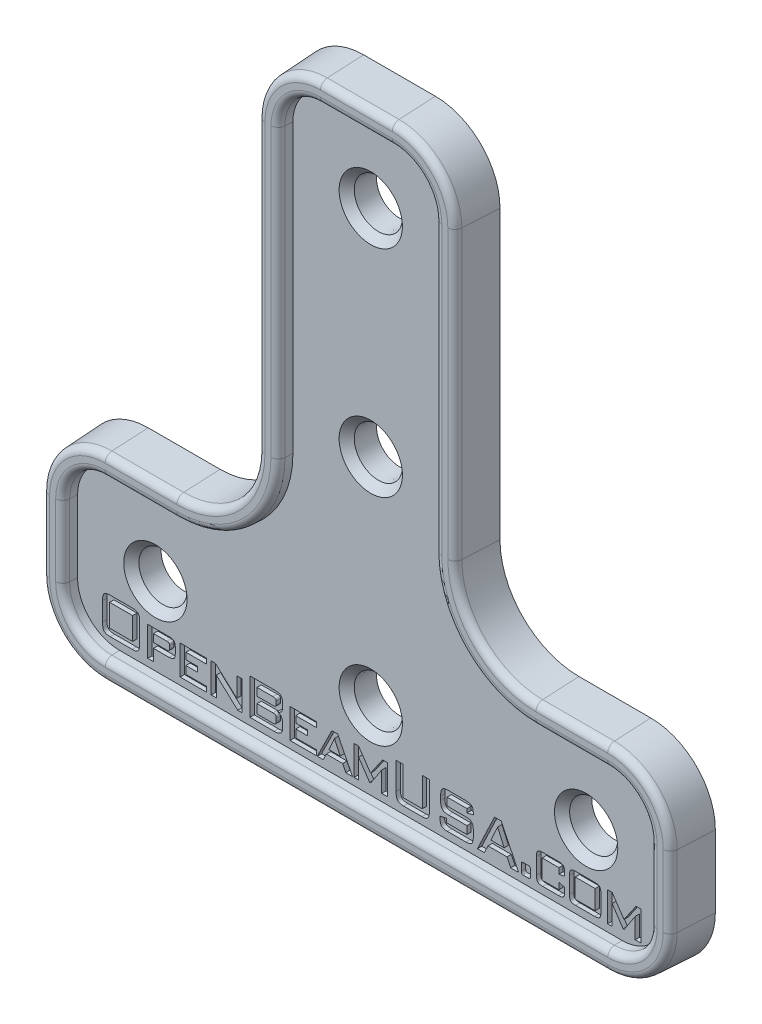
from build123d import *

# Parameters (mm, degrees)
BOSS_EXTRUDE1_DEPTH   = 2
FILLET1_R             = 5
SKETCH2_R             = 1.6
CUT_EXTRUDE1_DEPTH    = 38.553295461
MOVE_FACE1_BY         = 0.5
MOVE_FACE1_2_BY       = 0.5
MOVE_FACE1_3_BY       = 0.5
MOVE_FACE1_4_BY       = 0.5
MOVE_FACE1_5_BY       = 0.5
MOVE_FACE1_6_BY       = 0.5
MOVE_FACE1_7_BY       = 0.5
MOVE_FACE1_8_BY       = 0.5
MOVE_FACE1_9_BY       = 0.5
MOVE_FACE1_10_BY      = 0.5
MOVE_FACE1_11_BY      = 0.5
MOVE_FACE1_12_BY      = 0.5
MOVE_FACE1_13_BY      = 0.5
MOVE_FACE1_14_BY      = 0.5
MOVE_FACE1_15_BY      = 0.5
MOVE_FACE1_16_BY      = 0.5
DRAFT1_ANGLE          = -3
BOSS_EXTRUDE3_DEPTH   = 1
BOSS_EXTRUDE3_DRAFT   = 3
FILLET3_R             = 0.5
CUT_EXTRUDE2_DEPTH    = 0.2
CUT_EXTRUDE2_DRAFT    = -3
SKETCH6_W             = 1.607142857
SKETCH6_H             = 1.5625
SKETCH6_W_2           = 1.383928571
SKETCH6_H_2           = 1.339285714
CUT_EXTRUDE3_DEPTH    = 0.3
CHAMFER1_SIZE         = 0.5
CHAMFER1_SIZE2        = 0.528377251
CHAMFER1_EDGE_2_SIZE  = 0.5
CHAMFER1_EDGE_2_SIZE2 = 0.528377251
CHAMFER1_EDGE_3_SIZE  = 0.5
CHAMFER1_EDGE_3_SIZE2 = 0.528377251
CHAMFER1_EDGE_4_SIZE  = 0.5
CHAMFER1_EDGE_4_SIZE2 = 0.528377251
CHAMFER1_EDGE_5_SIZE  = 0.5
CHAMFER1_EDGE_5_SIZE2 = 0.528377251


with BuildPart() as part:
    # Sketch1 → Boss-Extrude1 (new body)
    with BuildSketch(Plane.XY):
        Polygon((-7.5, 30), (7.5, 30), (7.5, 0), (22.5, 0), (22.5, -15), (-22.5, -15), (-22.5, 0), (-7.5, 0), align=None)
    extrude(amount=BOSS_EXTRUDE1_DEPTH)

    # Fillet1
    fillet1_edges = [part.edges().sort_by_distance(p)[0] for p in [
        (-7.5, 30, 1),
        (7.5, 30, 1),
        (7.5, 0, 1),
        (22.5, 0, 1),
        (22.5, -15, 1),
        (-22.5, -15, 1),
        (-22.5, 0, 1),
        (-7.5, 0, 1),
    ]]
    fillet(fillet1_edges, radius=FILLET1_R)

    # Sketch2 → Cut-Extrude1 (cut, through all)
    with BuildSketch(Plane.XY.offset(2)):
        with Locations((-15, -7.5)):
            Circle(SKETCH2_R)
        with Locations((0, -7.5)):
            Circle(SKETCH2_R)
        with Locations((15, -7.5)):
            Circle(SKETCH2_R)
        with Locations((0, 22.5)):
            Circle(SKETCH2_R)
        with Locations((0, 7.5)):
            Circle(SKETCH2_R)
    extrude(amount=-CUT_EXTRUDE1_DEPTH, mode=Mode.SUBTRACT)

    # Move Face1: a curved face moved inward by 0.5
    add(Solid.thicken(part.faces().sort_by_distance((-8.964466094, 1.464466094, 1))[0], -MOVE_FACE1_BY), mode=Mode.SUBTRACT)

    # Move Face1 2: a face moved inward by 0.5
    extrude(part.faces().sort_by_distance((-15, 0, 1))[0], amount=MOVE_FACE1_2_BY, dir=(0, -1, 0), mode=Mode.SUBTRACT)

    # Move Face1 3: a curved face moved inward by 0.5
    add(Solid.thicken(part.faces().sort_by_distance((-21.035533906, -1.464466094, 1))[0], -MOVE_FACE1_3_BY), mode=Mode.SUBTRACT)

    # Move Face1 4: a face moved inward by 0.5
    extrude(part.faces().sort_by_distance((-22.5, -7.5, 1))[0], amount=MOVE_FACE1_4_BY, dir=(1, 0, 0), mode=Mode.SUBTRACT)

    # Move Face1 5: a curved face moved inward by 0.5
    add(Solid.thicken(part.faces().sort_by_distance((-21.035533906, -13.535533906, 1))[0], -MOVE_FACE1_5_BY), mode=Mode.SUBTRACT)

    # Move Face1 6: a face moved inward by 0.5
    extrude(part.faces().sort_by_distance((0, -15, 1))[0], amount=MOVE_FACE1_6_BY, dir=(0, 1, 0), mode=Mode.SUBTRACT)

    # Move Face1 7: a curved face moved inward by 0.5
    add(Solid.thicken(part.faces().sort_by_distance((21.035533906, -13.535533906, 1))[0], -MOVE_FACE1_7_BY), mode=Mode.SUBTRACT)

    # Move Face1 8: a face moved inward by 0.5
    extrude(part.faces().sort_by_distance((22.5, -7.5, 1))[0], amount=MOVE_FACE1_8_BY, dir=(-1, 0, 0), mode=Mode.SUBTRACT)

    # Move Face1 9: a curved face moved inward by 0.5
    add(Solid.thicken(part.faces().sort_by_distance((21.035533906, -1.464466094, 1))[0], -MOVE_FACE1_9_BY), mode=Mode.SUBTRACT)

    # Move Face1 10: a face moved inward by 0.5
    extrude(part.faces().sort_by_distance((15, 0, 1))[0], amount=MOVE_FACE1_10_BY, dir=(0, -1, 0), mode=Mode.SUBTRACT)

    # Move Face1 11: a curved face moved inward by 0.5
    add(Solid.thicken(part.faces().sort_by_distance((8.964466094, 1.464466094, 1))[0], -MOVE_FACE1_11_BY), mode=Mode.SUBTRACT)

    # Move Face1 12: a face moved inward by 0.5
    extrude(part.faces().sort_by_distance((7.5, 15, 1))[0], amount=MOVE_FACE1_12_BY, dir=(-1, 0, 0), mode=Mode.SUBTRACT)

    # Move Face1 13: a curved face moved inward by 0.5
    add(Solid.thicken(part.faces().sort_by_distance((6.035533906, 28.535533906, 1))[0], -MOVE_FACE1_13_BY), mode=Mode.SUBTRACT)

    # Move Face1 14: a face moved inward by 0.5
    extrude(part.faces().sort_by_distance((0, 30, 1))[0], amount=MOVE_FACE1_14_BY, dir=(0, -1, 0), mode=Mode.SUBTRACT)

    # Move Face1 15: a curved face moved inward by 0.5
    add(Solid.thicken(part.faces().sort_by_distance((-6.035533906, 28.535533906, 1))[0], -MOVE_FACE1_15_BY), mode=Mode.SUBTRACT)

    # Move Face1 16: a face moved inward by 0.5
    extrude(part.faces().sort_by_distance((-7.5, 15, 1))[0], amount=MOVE_FACE1_16_BY, dir=(1, 0, 0), mode=Mode.SUBTRACT)

    # Draft1
    draft1_faces = [part.faces().sort_by_distance(p)[0] for p in [
        (13.4, -7.5, 1),
        (-1.6, 22.5, 1),
        (-1.6, 7.5, 1),
        (-1.6, -7.5, 1),
        (-16.6, -7.5, 1),
        (-20.681980515, -1.818019485, 1),
        (-22, -7.5, 1),
        (-20.681980515, -13.181980515, 1),
        (0, -14.5, 1),
        (20.681980515, -13.181980515, 1),
        (22, -7.5, 1),
        (20.681980515, -1.818019485, 1),
        (15, -0.5, 1),
        (8.610912703, 1.110912703, 1),
        (7, 15, 1),
        (5.681980515, 28.181980515, 1),
        (0, 29.5, 1),
        (-5.681980515, 28.181980515, 1),
        (-7, 15, 1),
        (-8.610912703, 1.110912703, 1),
        (-15, -0.5, 1),
    ]]
    draft(draft1_faces, Plane(origin=(0, 0, 0), x_dir=(-1, 0, 0), z_dir=(0, 0, -1)), DRAFT1_ANGLE)


with BuildPart() as boss_extrude3_tool:
    # Sketch4 → Boss-Extrude3 (with draft: the straight prism first)
    with BuildSketch(Plane.XY.offset(2)):
        with BuildLine():
            Line((-17.5, -14.395184441), (17.5, -14.395184441))
            ThreePointArc((17.5, -14.395184441), (20.607864723, -13.107864723), (21.895184441, -10))
            Line((21.895184441, -10), (21.895184441, -5))
            ThreePointArc((21.895184441, -5), (20.607864723, -1.892135277), (17.5, -0.604815559))
            Line((17.5, -0.604815559), (12.5, -0.604815559))
            ThreePointArc((12.5, -0.604815559), (8.536796911, 1.036796911), (6.895184441, 5))
            Line((6.895184441, 5), (6.895184441, 25))
            ThreePointArc((6.895184441, 25), (5.607864723, 28.107864723), (2.5, 29.395184441))
            Line((2.5, 29.395184441), (-2.5, 29.395184441))
            ThreePointArc((-2.5, 29.395184441), (-5.607864723, 28.107864723), (-6.895184441, 25))
            Line((-6.895184441, 25), (-6.895184441, 5))
            ThreePointArc((-6.895184441, 5), (-8.536796911, 1.036796911), (-12.5, -0.604815559))
            Line((-12.5, -0.604815559), (-17.5, -0.604815559))
            ThreePointArc((-17.5, -0.604815559), (-20.607864723, -1.892135277), (-21.895184441, -5))
            Line((-21.895184441, -5), (-21.895184441, -10))
            ThreePointArc((-21.895184441, -10), (-20.607864723, -13.107864723), (-17.5, -14.395184441))
        make_face()
        with BuildLine():
            Line((-17.5, -12.921388331), (17.5, -12.921388331))
            ThreePointArc((17.5, -12.921388331), (19.565733499, -12.065733499), (20.421388331, -10))
            Line((20.421388331, -10), (20.421388331, -5))
            ThreePointArc((20.421388331, -5), (19.565733499, -2.934266501), (17.5, -2.078611669))
            Line((17.5, -2.078611669), (12.5, -2.078611669))
            ThreePointArc((12.5, -2.078611669), (7.494665688, -0.005334312), (5.421388331, 5))
            Line((5.421388331, 5), (5.421388331, 25))
            ThreePointArc((5.421388331, 25), (4.565733499, 27.065733499), (2.5, 27.921388331))
            Line((2.5, 27.921388331), (-2.5, 27.921388331))
            ThreePointArc((-2.5, 27.921388331), (-4.565733499, 27.065733499), (-5.421388331, 25))
            Line((-5.421388331, 25), (-5.421388331, 5))
            ThreePointArc((-5.421388331, 5), (-7.494665688, -0.005334312), (-12.5, -2.078611669))
            Line((-12.5, -2.078611669), (-17.5, -2.078611669))
            ThreePointArc((-17.5, -2.078611669), (-19.565733499, -2.934266501), (-20.421388331, -5))
            Line((-20.421388331, -5), (-20.421388331, -10))
            ThreePointArc((-20.421388331, -10), (-19.565733499, -12.065733499), (-17.5, -12.921388331))
        make_face(mode=Mode.SUBTRACT)
    extrude(amount=BOSS_EXTRUDE3_DEPTH)
    # Boss-Extrude3: the draft: its side faces are tilted about the plane it starts from
    boss_extrude3_sides = [boss_extrude3_tool.faces().sort_by_distance(p)[0] for p in [
        (-20.607864723, -1.892135277, 2.5),
        (-21.895184441, -7.5, 2.5),
        (-20.607864723, -13.107864723, 2.5),
        (0, -14.395184441, 2.5),
        (20.607864723, -13.107864723, 2.5),
        (21.895184441, -7.5, 2.5),
        (20.607864723, -1.892135277, 2.5),
        (15, -0.604815559, 2.5),
        (8.536796911, 1.036796911, 2.5),
        (6.895184441, 15, 2.5),
        (5.607864723, 28.107864723, 2.5),
        (0, 29.395184441, 2.5),
        (-5.607864723, 28.107864723, 2.5),
        (-6.895184441, 15, 2.5),
        (-8.536796911, 1.036796911, 2.5),
        (-15, -0.604815559, 2.5),
        (-15, -2.078611669, 2.5),
        (-7.494665688, -0.005334312, 2.5),
        (-5.421388331, 15, 2.5),
        (-4.565733499, 27.065733499, 2.5),
        (0, 27.921388331, 2.5),
        (4.565733499, 27.065733499, 2.5),
        (5.421388331, 15, 2.5),
        (7.494665688, -0.005334312, 2.5),
        (15, -2.078611669, 2.5),
        (19.565733499, -2.934266501, 2.5),
        (20.421388331, -7.5, 2.5),
        (19.565733499, -12.065733499, 2.5),
        (0, -12.921388331, 2.5),
        (-19.565733499, -12.065733499, 2.5),
        (-20.421388331, -7.5, 2.5),
        (-19.565733499, -2.934266501, 2.5),
    ]]
    draft(boss_extrude3_sides, Plane.XY.offset(2), BOSS_EXTRUDE3_DRAFT)


with BuildPart() as part_1:
    add(part.part)

    # Boss-Extrude3: add boss_extrude3_tool
    add(boss_extrude3_tool.part)

    # Fillet3
    fillet3_edges = [part_1.edges().sort_by_distance(p)[0] for p in [
        (-20.570806827, -13.070806827, 3),
        (0, -14.342776662, 3),
        (20.570806827, -13.070806827, 3),
        (21.842776662, -7.5, 3),
        (20.570806827, -1.929193173, 3),
        (15, -0.657223338, 3),
        (8.499739015, 0.999739015, 3),
        (6.842776662, 15, 3),
        (5.570806827, 28.070806827, 3),
        (0, 29.342776662, 3),
        (-5.570806827, 28.070806827, 3),
        (-6.842776662, 15, 3),
        (-8.499739015, 0.999739015, 3),
        (-15, -0.657223338, 3),
        (-20.570806827, -1.929193173, 3),
        (-21.842776662, -7.5, 3),
        (-19.602791396, -12.102791396, 3),
        (0, -12.97379611, 3),
        (19.602791396, -12.102791396, 3),
        (20.47379611, -7.5, 3),
        (19.602791396, -2.897208604, 3),
        (15, -2.02620389, 3),
        (7.531723584, 0.031723584, 3),
        (5.47379611, 15, 3),
        (4.602791396, 27.102791396, 3),
        (0, 27.97379611, 3),
        (-4.602791396, 27.102791396, 3),
        (-5.47379611, 15, 3),
        (-7.531723584, 0.031723584, 3),
        (-15, -2.02620389, 3),
        (-19.602791396, -2.897208604, 3),
        (-20.47379611, -7.5, 3),
    ]]
    fillet(fillet3_edges, radius=FILLET3_R)


with BuildPart() as cut_extrude2_tool:
    # Sketch5 → Cut-Extrude2 (with draft: the straight prism first)
    with BuildSketch(Plane(origin=(0, 0, 0), x_dir=(-1, 0, 0), z_dir=(0, 0, -1))):
        with BuildLine():
            Line((-14.5, -13.8), (14.5, -13.8))
            ThreePointArc((14.5, -13.8), (14.853553391, -13.653553391), (15, -13.3))
            Line((15, -13.3), (15, -10.3))
            ThreePointArc((15, -10.3), (14.853553391, -9.946446609), (14.5, -9.8))
            Line((14.5, -9.8), (-14.5, -9.8))
            ThreePointArc((-14.5, -9.8), (-14.853553391, -9.946446609), (-15, -10.3))
            Line((-15, -10.3), (-15, -13.3))
            ThreePointArc((-15, -13.3), (-14.853553391, -13.653553391), (-14.5, -13.8))
        make_face()
    extrude(amount=-CUT_EXTRUDE2_DEPTH)
    # Cut-Extrude2: the draft: its side faces are tilted about the plane it starts from
    cut_extrude2_sides = [cut_extrude2_tool.faces().sort_by_distance(p)[0] for p in [
        (0, -13.8, 0.1),
        (-14.853553391, -13.653553391, 0.1),
        (-15, -11.8, 0.1),
        (-14.853553391, -9.946446609, 0.1),
        (0, -9.8, 0.1),
        (14.853553391, -9.946446609, 0.1),
        (15, -11.8, 0.1),
        (14.853553391, -13.653553391, 0.1),
    ]]
    draft(cut_extrude2_sides, Plane(origin=(0, 0, 0), x_dir=(-1, 0, 0), z_dir=(0, 0, -1)), CUT_EXTRUDE2_DRAFT)


with BuildPart() as part_2:
    add(part_1.part)

    # Cut-Extrude2: cut by cut_extrude2_tool
    add(cut_extrude2_tool.part, mode=Mode.SUBTRACT)

    # Sketch6 → Cut-Extrude3 (cut)
    with BuildSketch(Plane.XY.offset(2)):
        with BuildLine():
            add(Edge.make_bspline(
                [(-18.683035714, -10.51011601), (-18.682938002, -10.482896819), (-18.682750693, -10.430719031), (-18.676668044, -10.356042819), (-18.668860697, -10.287926096), (-18.656684431, -10.226526586), (-18.643031263, -10.171215857), (-18.623628363, -10.123356935), (-18.602261682, -10.081592118), (-18.57683028, -10.045679654), (-18.545847467, -10.01549167), (-18.508789269, -9.990400409), (-18.46597857, -9.968617372), (-18.416580048, -9.951568957), (-18.361320255, -9.937537726), (-18.299893333, -9.928095322), (-18.232289845, -9.922620499), (-18.185232384, -9.921811984), (-18.160574777, -9.921388331)],
                knots=[0, 0, 0, 0, 1.403573437, 2.690578007, 3.862923789, 4.937964027, 5.918444779, 6.796020214, 7.595440406, 8.334448064, 9.055422419, 9.814027648, 10.634759978, 11.526322857, 12.50379092, 13.57259004, 14.728063101, 16, 16, 16, 16], degree=3))
            Line((-18.160574777, -9.921388331), (-16.618303571, -9.921388331))
            add(Edge.make_bspline(
                [(-16.618303571, -9.921388331), (-16.593646851, -9.921821445), (-16.546359359, -9.922652086), (-16.47851397, -9.928042886), (-16.416866585, -9.937552288), (-16.361581808, -9.951531158), (-16.312067564, -9.968807094), (-16.268818434, -9.990195221), (-16.231663242, -10.015520924), (-16.200589368, -10.045644028), (-16.175401388, -10.081803336), (-16.152770043, -10.122971899), (-16.134936302, -10.1715459), (-16.119750579, -10.226353255), (-16.108035577, -10.28796068), (-16.100083866, -10.356032245), (-16.094044728, -10.430722068), (-16.09385104, -10.48289786), (-16.09375, -10.51011601)],
                knots=[0, 0, 0, 0, 1.269785572, 2.435237667, 3.502229043, 4.478043838, 5.368098746, 6.198135559, 6.9554577, 7.675212615, 8.41297033, 9.216677895, 10.088421144, 11.070387939, 12.143609877, 13.313972779, 14.598800537, 16, 16, 16, 16], degree=3))
            Line((-16.09375, -10.51011601), (-16.09375, -11.811036769))
            add(Edge.make_bspline(
                [(-16.09375, -11.811036769), (-16.093842278, -11.839417739), (-16.09401872, -11.893684241), (-16.100160957, -11.971615929), (-16.107923834, -12.042494992), (-16.119768025, -12.106636793), (-16.134983627, -12.163512713), (-16.152647685, -12.213987832), (-16.175226782, -12.256626432), (-16.200584268, -12.293600425), (-16.231614851, -12.324447097), (-16.268765478, -12.35050105), (-16.312034652, -12.372539497), (-16.361440049, -12.390711436), (-16.416882029, -12.404519647), (-16.478547615, -12.413833116), (-16.546317858, -12.420380788), (-16.593639586, -12.421043123), (-16.618303571, -12.421388331)],
                knots=[0, 0, 0, 0, 1.431764632, 2.737639174, 3.942781974, 5.02906717, 6.025299976, 6.912532689, 7.72083079, 8.453349384, 9.16691991, 9.91579719, 10.734504626, 11.610727997, 12.566975227, 13.612570717, 14.755676853, 16, 16, 16, 16], degree=3))
            Line((-16.618303571, -12.421388331), (-18.160574777, -12.421388331))
            add(Edge.make_bspline(
                [(-18.160574777, -12.421388331), (-18.185239843, -12.421053786), (-18.232332055, -12.420415051), (-18.299858951, -12.413778337), (-18.36130513, -12.404534983), (-18.416721056, -12.39067324), (-18.466016648, -12.372733543), (-18.508837175, -12.350292386), (-18.545896228, -12.324476536), (-18.576835987, -12.293565989), (-18.602437267, -12.256831275), (-18.623739569, -12.213611433), (-18.642993476, -12.163833364), (-18.656664691, -12.106469119), (-18.668974999, -12.042529082), (-18.676590443, -11.971605588), (-18.682776858, -11.893687213), (-18.682946824, -11.83941876), (-18.683035714, -11.811036769)],
                knots=[0, 0, 0, 0, 1.246375741, 2.37966474, 3.42698501, 4.384809634, 5.262478393, 6.072109836, 6.82222244, 7.536970048, 8.27069698, 9.074935671, 9.967741802, 10.962637047, 12.050714143, 13.257844907, 14.565873577, 16, 16, 16, 16], degree=3))
            Line((-18.683035714, -11.811036769), (-18.683035714, -10.51011601))
        make_face()
        with Locations((-17.388392858, -11.149066903)):
            Rectangle(SKETCH6_W, SKETCH6_H, mode=Mode.SUBTRACT)
        with BuildLine():
            Line((-15.535714286, -12.421388331), (-15.535714286, -10.367816903))
            Line((-15.535714286, -10.367816903), (-14.029715402, -10.367816903))
            add(Edge.make_bspline(
                [(-14.029715402, -10.367816903), (-13.995423097, -10.368539056), (-13.931618582, -10.369882701), (-13.843548193, -10.388389773), (-13.76975323, -10.416602804), (-13.710808728, -10.459570634), (-13.666606985, -10.516609772), (-13.63694694, -10.588263693), (-13.619168575, -10.67387452), (-13.617150642, -10.735791272), (-13.616071429, -10.768905072)],
                knots=[0, 0, 0, 0, 1.229947315, 2.288449038, 3.21776736, 4.048244043, 4.875520742, 5.777278643, 6.811262717, 8, 8, 8, 8], degree=3))
            Line((-13.616071429, -10.768905072), (-13.616071429, -11.216728733))
            add(Edge.make_bspline(
                [(-13.616071429, -11.216728733), (-13.61713941, -11.249840567), (-13.619129003, -11.311526162), (-13.637004149, -11.397243648), (-13.667259143, -11.468686782), (-13.711509006, -11.52635012), (-13.770938209, -11.568616699), (-13.844372756, -11.597454165), (-13.932113653, -11.615653184), (-13.995666115, -11.617062069), (-14.029715402, -11.617816903)],
                knots=[0, 0, 0, 0, 1.189703839, 2.216355318, 3.129857055, 3.957806409, 4.795702339, 5.718039216, 6.7774016, 8, 8, 8, 8], degree=3))
            Line((-14.029715402, -11.617816903), (-15.133928571, -11.617816903))
            Line((-15.133928571, -11.617816903), (-15.133928571, -12.421388331))
            Line((-15.133928571, -12.421388331), (-15.535714286, -12.421388331))
        make_face()
        with BuildLine():
            Line((-14.203404018, -10.72495976), (-15.133928571, -10.72495976))
            Line((-15.133928571, -10.72495976), (-15.133928571, -11.260674045))
            Line((-15.133928571, -11.260674045), (-14.203404018, -11.260674045))
            add(Edge.make_bspline(
                [(-14.203404018, -11.260674045), (-14.187098835, -11.260411914), (-14.157096885, -11.259929586), (-14.115874448, -11.253123203), (-14.082698889, -11.241865943), (-14.056496441, -11.22503593), (-14.038862603, -11.201230006), (-14.025790126, -11.172314024), (-14.019621299, -11.136752914), (-14.018473493, -11.11118051), (-14.017857143, -11.097448599)],
                knots=[0, 0, 0, 0, 1.352116432, 2.487928597, 3.45245427, 4.244622693, 5.028283095, 5.874769735, 6.858790467, 8, 8, 8, 8], degree=3))
            Line((-14.017857143, -11.097448599), (-14.017857143, -10.888185206))
            add(Edge.make_bspline(
                [(-14.017857143, -10.888185206), (-14.018466943, -10.874447349), (-14.01960255, -10.848863871), (-14.025849613, -10.813373783), (-14.038604854, -10.784405633), (-14.05696494, -10.76134583), (-14.082395639, -10.743581231), (-14.115935147, -10.732589069), (-14.157077073, -10.725678609), (-14.187091859, -10.725212873), (-14.203404018, -10.72495976)],
                knots=[0, 0, 0, 0, 1.141800926, 2.126331593, 2.973256896, 3.742199929, 4.545756613, 5.510782118, 6.64718288, 8, 8, 8, 8], degree=3))
        make_face(mode=Mode.SUBTRACT)
        Polygon((-13.28125, -12.421388331), (-13.28125, -10.367816903), (-11.450892857, -10.367816903), (-11.450892857, -10.72495976), (-12.879464286, -10.72495976), (-12.879464286, -11.171388331), (-12.075892857, -11.171388331), (-12.075892857, -11.528531188), (-12.879464286, -11.528531188), (-12.879464286, -12.064245474), (-11.450892857, -12.064245474), (-11.450892857, -12.421388331), align=None)
        Polygon((-11.116071429, -12.421388331), (-11.116071429, -10.367816903), (-10.821707589, -10.367816903), (-9.330357143, -11.731516679), (-9.330357143, -10.367816903), (-8.973214286, -10.367816903), (-8.973214286, -12.421388331), (-9.269670759, -12.421388331), (-10.758928571, -11.036762215), (-10.758928571, -12.421388331), align=None)
        with BuildLine():
            Line((-8.415178571, -12.421388331), (-8.415178571, -9.921388331))
            Line((-8.415178571, -9.921388331), (-6.604352679, -9.921388331))
            add(Edge.make_bspline(
                [(-6.604352679, -9.921388331), (-6.584578843, -9.921834875), (-6.546344475, -9.922698306), (-6.490993159, -9.928039701), (-6.439967327, -9.937982556), (-6.392984602, -9.950745963), (-6.350485334, -9.96859511), (-6.312122888, -9.989884555), (-6.278270641, -10.015636971), (-6.247499297, -10.044225626), (-6.221859971, -10.078333565), (-6.199342826, -10.116212883), (-6.180626562, -10.158719559), (-6.16430305, -10.205449169), (-6.152784019, -10.257462736), (-6.1448266, -10.313921043), (-6.13872257, -10.37466268), (-6.138505034, -10.416628349), (-6.138392857, -10.438268911)],
                knots=[0, 0, 0, 0, 1.179053587, 2.27979888, 3.310209753, 4.275627239, 5.176695408, 6.051906754, 6.883661987, 7.707291014, 8.547436998, 9.417583548, 10.329674368, 11.311670144, 12.364223081, 13.499348066, 14.710481303, 16, 16, 16, 16], degree=3))
            Line((-6.138392857, -10.438268911), (-6.138392857, -10.712403956))
            add(Edge.make_bspline(
                [(-6.138392857, -10.712403956), (-6.139201585, -10.740664602), (-6.140751158, -10.794813763), (-6.159801787, -10.871364096), (-6.188653758, -10.939999278), (-6.231476997, -10.9984646), (-6.284875183, -11.04779488), (-6.349361396, -11.086101447), (-6.424010981, -11.11446387), (-6.477873721, -11.124365422), (-6.505998884, -11.129535653)],
                knots=[0, 0, 0, 0, 1.098733523, 2.105242008, 3.054667811, 3.982622784, 4.906010345, 5.869427447, 6.887492557, 8, 8, 8, 8], degree=3))
            add(Edge.make_bspline(
                [(-6.505998884, -11.129535653), (-6.478036354, -11.135503517), (-6.424069928, -11.147021228), (-6.349494996, -11.180530422), (-6.285840082, -11.227562783), (-6.231981261, -11.286146859), (-6.190215279, -11.356411535), (-6.158931917, -11.436113578), (-6.142041656, -11.526206522), (-6.139644104, -11.589151907), (-6.138392857, -11.62200217)],
                knots=[0, 0, 0, 0, 1.013460027, 1.955932307, 2.877588656, 3.806945104, 4.76292404, 5.764334755, 6.833239427, 8, 8, 8, 8], degree=3))
            Line((-6.138392857, -11.62200217), (-6.138392857, -11.935199715))
            add(Edge.make_bspline(
                [(-6.138392857, -11.935199715), (-6.138719134, -11.95521589), (-6.1393511, -11.993985259), (-6.146352988, -12.050089823), (-6.158290901, -12.101885834), (-6.174184983, -12.150022339), (-6.195462804, -12.19402501), (-6.220131016, -12.234909748), (-6.250938229, -12.270878361), (-6.285794672, -12.303013122), (-6.32562112, -12.331371608), (-6.370173139, -12.355556185), (-6.41960395, -12.375811734), (-6.47355595, -12.392422759), (-6.532276629, -12.405800235), (-6.595779264, -12.414401622), (-6.66400309, -12.420183393), (-6.71106383, -12.420976607), (-6.735491071, -12.421388331)],
                knots=[0, 0, 0, 0, 1.08782081, 2.107002258, 3.066832627, 3.974287218, 4.856380914, 5.719335199, 6.562621095, 7.421491684, 8.291454475, 9.213583009, 10.171413382, 11.190986747, 12.279688622, 13.441734262, 14.672112383, 16, 16, 16, 16], degree=3))
            Line((-6.735491071, -12.421388331), (-8.415178571, -12.421388331))
        make_face()
        with BuildLine():
            Line((-6.809430804, -10.367816903), (-7.924107143, -10.367816903))
            Line((-7.924107143, -10.367816903), (-7.924107143, -10.903531188))
            Line((-7.924107143, -10.903531188), (-6.809430804, -10.903531188))
            add(Edge.make_bspline(
                [(-6.809430804, -10.903531188), (-6.789868986, -10.903287406), (-6.753850642, -10.902838541), (-6.704705771, -10.895868934), (-6.664727575, -10.885532078), (-6.633451466, -10.869144346), (-6.610525171, -10.846199776), (-6.594844818, -10.816925235), (-6.585991347, -10.781273052), (-6.585228551, -10.755471654), (-6.584821429, -10.741700831)],
                knots=[0, 0, 0, 0, 1.458061766, 2.684667078, 3.694961047, 4.525618309, 5.286113602, 6.078010599, 6.974188284, 8, 8, 8, 8], degree=3))
            Line((-6.584821429, -10.741700831), (-6.584821429, -10.52964726))
            add(Edge.make_bspline(
                [(-6.584821429, -10.52964726), (-6.585215601, -10.516102183), (-6.585953486, -10.490746024), (-6.594997769, -10.455637651), (-6.610492176, -10.426504554), (-6.633624093, -10.40365479), (-6.664600507, -10.386469448), (-6.704601516, -10.375280427), (-6.753863487, -10.36857796), (-6.789873506, -10.368084762), (-6.809430804, -10.367816903)],
                knots=[0, 0, 0, 0, 1.011123078, 1.892805606, 2.686758123, 3.449227428, 4.290532683, 5.308364354, 6.538153555, 8, 8, 8, 8], degree=3))
        make_face(mode=Mode.SUBTRACT)
        with BuildLine():
            Line((-6.809430804, -11.34995976), (-7.924107143, -11.34995976))
            Line((-7.924107143, -11.34995976), (-7.924107143, -11.97495976))
            Line((-7.924107143, -11.97495976), (-6.809430804, -11.97495976))
            add(Edge.make_bspline(
                [(-6.809430804, -11.97495976), (-6.78912971, -11.974729537), (-6.751959866, -11.974308016), (-6.701848603, -11.964050408), (-6.661008099, -11.950556293), (-6.630050641, -11.927619568), (-6.609123919, -11.895827935), (-6.594863374, -11.856463039), (-6.585878103, -11.808409349), (-6.585191715, -11.773414396), (-6.584821429, -11.754535653)],
                knots=[0, 0, 0, 0, 1.312342557, 2.402804986, 3.304020979, 4.078546667, 4.847629795, 5.734752509, 6.777965855, 8, 8, 8, 8], degree=3))
            Line((-6.584821429, -11.754535653), (-6.584821429, -11.568291233))
            add(Edge.make_bspline(
                [(-6.584821429, -11.568291233), (-6.585200764, -11.549416114), (-6.585903926, -11.514427881), (-6.594743125, -11.466546068), (-6.609130884, -11.427679287), (-6.630070466, -11.396444881), (-6.661397726, -11.374656265), (-6.701546197, -11.359680216), (-6.752105393, -11.35100656), (-6.789165763, -11.350329813), (-6.809430804, -11.34995976)],
                knots=[0, 0, 0, 0, 1.227068129, 2.274578833, 3.151237288, 3.911086288, 4.679771909, 5.590123259, 6.682251448, 8, 8, 8, 8], degree=3))
        make_face(mode=Mode.SUBTRACT)
        Polygon((-5.625, -12.421388331), (-5.625, -10.367816903), (-3.794642857, -10.367816903), (-3.794642857, -10.72495976), (-5.223214286, -10.72495976), (-5.223214286, -11.171388331), (-4.419642857, -11.171388331), (-4.419642857, -11.528531188), (-5.223214286, -11.528531188), (-5.223214286, -12.064245474), (-3.794642857, -12.064245474), (-3.794642857, -12.421388331), align=None)
        Polygon((-3.727678571, -12.421388331), (-2.709263393, -10.367816903), (-2.306780134, -10.367816903), (-1.272321429, -12.421388331), (-1.741768973, -12.421388331), (-1.958007812, -11.97495976), (-3.093610491, -11.97495976), (-3.30984933, -12.421388331), align=None)
        Polygon((-2.915039062, -11.617816903), (-2.128208705, -11.617816903), (-2.52859933, -10.746583644), align=None, mode=Mode.SUBTRACT)
        Polygon((-1.160714286, -12.421388331), (-1.160714286, -10.367816903), (-0.848214286, -10.367816903), (-0.017438616, -11.586427394), (0.822405134, -10.367816903), (1.160714286, -10.367816903), (1.160714286, -12.421388331), (0.758928571, -12.421388331), (0.758928571, -11.008162885), (0.000697545, -12.174457528), (-0.080217634, -12.174457528), (-0.848214286, -11.040947483), (-0.848214286, -12.421388331), align=None)
        with BuildLine():
            Line((2.254464286, -9.921388331), (2.254464286, -11.930316903))
            Line((2.254464286, -11.930316903), (3.59375, -11.930316903))
            Line((3.59375, -11.930316903), (3.59375, -9.921388331))
            Line((3.59375, -9.921388331), (4.084821429, -9.921388331))
            Line((4.084821429, -9.921388331), (4.084821429, -11.811036769))
            add(Edge.make_bspline(
                [(4.084821429, -11.811036769), (4.084729151, -11.83941774), (4.08455271, -11.893684242), (4.078410469, -11.971615924), (4.070647603, -12.042495008), (4.058803376, -12.106636741), (4.043587889, -12.163512882), (4.025923466, -12.213987296), (4.003345545, -12.256628171), (3.977984177, -12.293594652), (3.946967658, -12.32446853), (3.909930317, -12.35029481), (3.867103299, -12.37273261), (3.817809766, -12.390674382), (3.762392801, -12.404530974), (3.700719574, -12.413829665), (3.632951625, -12.420381775), (3.585629562, -12.421043461), (3.560965402, -12.421388331)],
                knots=[0, 0, 0, 0, 1.432696721, 2.739421396, 3.945348753, 5.032341128, 6.029222489, 6.917032796, 7.725857105, 8.458852573, 9.172887639, 9.922252443, 10.731076752, 11.60787055, 12.564740304, 13.611016484, 14.75486679, 16, 16, 16, 16], degree=3))
            Line((3.560965402, -12.421388331), (2.28515625, -12.421388331))
            add(Edge.make_bspline(
                [(2.28515625, -12.421388331), (2.260725019, -12.421041479), (2.213867868, -12.420376245), (2.146787965, -12.413857345), (2.085611417, -12.404422129), (2.030586419, -12.390821903), (1.981612193, -12.372601766), (1.938902995, -12.350085944), (1.901310533, -12.324703811), (1.870249293, -12.29356777), (1.844862961, -12.25663627), (1.822292601, -12.2139848), (1.804625834, -12.16351367), (1.789411083, -12.106636498), (1.777566629, -12.042495084), (1.769803833, -11.971615901), (1.763661571, -11.893684249), (1.763485133, -11.839417742), (1.763392857, -11.811036769)],
                knots=[0, 0, 0, 0, 1.23621022, 2.370952548, 3.407995083, 4.367048021, 5.234819768, 6.045489481, 6.806183598, 7.521847799, 8.256515662, 9.067185375, 9.957021301, 10.956177136, 12.045649581, 13.254328369, 14.564034454, 16, 16, 16, 16], degree=3))
            Line((1.763392857, -11.811036769), (1.763392857, -9.921388331))
            Line((1.763392857, -9.921388331), (2.254464286, -9.921388331))
        make_face()
        with BuildLine():
            Line((6.696428571, -10.367816903), (5.3125, -10.367816903))
            Line((5.3125, -10.367816903), (5.3125, -10.903531188))
            Line((5.3125, -10.903531188), (6.63016183, -10.903531188))
            add(Edge.make_bspline(
                [(6.63016183, -10.903531188), (6.654353014, -10.903958949), (6.700479225, -10.904774577), (6.766713326, -10.910183332), (6.826905144, -10.919870583), (6.881304458, -10.93330079), (6.92929363, -10.951844001), (6.971690494, -10.973066465), (7.007619207, -10.999097146), (7.038065694, -11.029410299), (7.063642091, -11.06526319), (7.084974932, -11.107481732), (7.103195036, -11.156136605), (7.117397219, -11.211638562), (7.129343814, -11.273803544), (7.137366908, -11.3428083), (7.142315022, -11.418477621), (7.142671297, -11.471091459), (7.142857143, -11.498536769)],
                knots=[0, 0, 0, 0, 1.251664019, 2.386593346, 3.434812074, 4.403525499, 5.279339231, 6.091802716, 6.849802477, 7.564361493, 8.305564064, 9.118027549, 10.005088541, 10.988481401, 12.078528828, 13.278238635, 14.580229349, 16, 16, 16, 16], degree=3))
            Line((7.142857143, -11.498536769), (7.142857143, -11.820802394))
            add(Edge.make_bspline(
                [(7.142857143, -11.820802394), (7.142670907, -11.848480082), (7.142313758, -11.90155824), (7.137365743, -11.977924663), (7.1293358, -12.047622044), (7.117402599, -12.110490083), (7.103150126, -12.166658376), (7.085162413, -12.215888413), (7.063443653, -12.258367141), (7.038074605, -12.294750102), (7.0078556, -12.325841034), (6.971643631, -12.351775421), (6.929450865, -12.373242409), (6.881137779, -12.390741413), (6.826858606, -12.40421072), (6.766788679, -12.414980112), (6.70046859, -12.42007351), (6.654349355, -12.420935995), (6.63016183, -12.421388331)],
                knots=[0, 0, 0, 0, 1.424071459, 2.730975543, 3.936089492, 5.032008831, 6.021662612, 6.915142695, 7.723221153, 8.470166276, 9.189379185, 9.94328787, 10.751366328, 11.61825191, 12.581736995, 13.626287574, 14.755091461, 16, 16, 16, 16], degree=3))
            Line((6.63016183, -12.421388331), (5.324358259, -12.421388331))
            add(Edge.make_bspline(
                [(5.324358259, -12.421388331), (5.300866876, -12.420931359), (5.255674503, -12.420052242), (5.190533843, -12.414925726), (5.131530179, -12.404487117), (5.078393092, -12.390307101), (5.030932807, -12.373619972), (4.989668753, -12.35157881), (4.954294363, -12.325618915), (4.924073733, -12.294956748), (4.899449082, -12.258298175), (4.878544743, -12.215717937), (4.860436506, -12.166672042), (4.845991982, -12.110563995), (4.835216036, -12.047531968), (4.826837919, -11.97793932), (4.821995382, -11.901554055), (4.821622836, -11.848478648), (4.821428571, -11.820802394)],
                knots=[0, 0, 0, 0, 1.219667072, 2.346377425, 3.388230707, 4.325160294, 5.199674189, 5.993493179, 6.744299279, 7.46984103, 8.21646325, 9.026182912, 9.927525331, 10.925887746, 12.029274189, 13.244992753, 14.563397171, 16, 16, 16, 16], degree=3))
            Line((4.821428571, -11.820802394), (4.821428571, -11.75872092))
            Line((4.821428571, -11.75872092), (5.267857143, -11.66245976))
            Line((5.267857143, -11.66245976), (5.267857143, -11.930316903))
            Line((5.267857143, -11.930316903), (6.696428571, -11.930316903))
            Line((6.696428571, -11.930316903), (6.696428571, -11.394602617))
            Line((6.696428571, -11.394602617), (5.406668527, -11.394602617))
            add(Edge.make_bspline(
                [(5.406668527, -11.394602617), (5.381318621, -11.394142187), (5.332646449, -11.393258156), (5.262625271, -11.38820715), (5.199039968, -11.377517598), (5.141836488, -11.363824902), (5.090670769, -11.346784404), (5.046603427, -11.324170198), (5.008215836, -11.298389637), (4.97572848, -11.267778264), (4.949636871, -11.230568829), (4.926561464, -11.188113753), (4.907738712, -11.138304217), (4.89305814, -11.081840424), (4.880014688, -11.018833425), (4.872516201, -10.948772379), (4.866340152, -10.872018433), (4.86616349, -10.818446253), (4.866071429, -10.790528956)],
                knots=[0, 0, 0, 0, 1.269118906, 2.436725934, 3.510156791, 4.492522834, 5.379601377, 6.202018549, 6.963898946, 7.688320218, 8.421662355, 9.228867506, 10.102094215, 11.078998209, 12.147242463, 13.319481032, 14.603139802, 16, 16, 16, 16], degree=3))
            Line((4.866071429, -10.790528956), (4.866071429, -10.512906188))
            add(Edge.make_bspline(
                [(4.866071429, -10.512906188), (4.866168727, -10.485686466), (4.866356072, -10.43327569), (4.872507781, -10.358146186), (4.880016723, -10.289478223), (4.89301151, -10.227844707), (4.907893802, -10.172615002), (4.926346791, -10.123783283), (4.949852356, -10.082499353), (4.975700358, -10.04602468), (5.008481655, -10.016282414), (5.046389433, -9.990260801), (5.090887408, -9.968693775), (5.141807749, -9.951449339), (5.198979833, -9.937581032), (5.262701901, -9.928047641), (5.332635014, -9.922656793), (5.381314705, -9.921822734), (5.406668527, -9.921388331)],
                knots=[0, 0, 0, 0, 1.377632593, 2.652591195, 3.814954431, 4.872421982, 5.83787301, 6.710181857, 7.506051987, 8.238342604, 8.963022824, 9.733676968, 10.56030012, 11.457594181, 12.451273063, 13.535212947, 14.716266034, 16, 16, 16, 16], degree=3))
            Line((5.406668527, -9.921388331), (6.606445313, -9.921388331))
            add(Edge.make_bspline(
                [(6.606445313, -9.921388331), (6.630871508, -9.921807846), (6.677930234, -9.92261607), (6.745479683, -9.928236239), (6.807133727, -9.936888325), (6.862778268, -9.950065049), (6.91249593, -9.967560204), (6.956687775, -9.988232319), (6.995178384, -10.012838845), (7.027760105, -10.041925314), (7.055736906, -10.075759055), (7.07966266, -10.115155119), (7.098382083, -10.160900236), (7.115935242, -10.211649019), (7.127570867, -10.2686675), (7.13703729, -10.331263883), (7.141354413, -10.399846619), (7.142342132, -10.447566677), (7.142857143, -10.472448599)],
                knots=[0, 0, 0, 0, 1.296779316, 2.498333482, 3.59650498, 4.599589076, 5.528850417, 6.390279385, 7.1847031, 7.945414428, 8.699384315, 9.508162524, 10.381888205, 11.318826147, 12.355238386, 13.465624049, 14.678540085, 16, 16, 16, 16], degree=3))
            Line((7.142857143, -10.472448599), (7.142857143, -10.521974269))
            Line((7.142857143, -10.521974269), (6.696428571, -10.635674045))
            Line((6.696428571, -10.635674045), (6.696428571, -10.367816903))
        make_face()
        Polygon((7.433035714, -12.421388331), (8.618861607, -9.921388331), (9.088309152, -9.921388331), (10.290178571, -12.421388331), (9.742606027, -12.421388331), (9.490792411, -11.885674045), (8.162667411, -11.885674045), (7.918526786, -12.421388331), align=None)
        Polygon((8.370535714, -11.439245474), (9.289202009, -11.439245474), (8.836495536, -10.41106467), align=None, mode=Mode.SUBTRACT)
        with BuildLine():
            Line((10.947265625, -11.66245976), (11.019810268, -11.66245976))
            add(Edge.make_bspline(
                [(11.019810268, -11.66245976), (11.027999823, -11.662762392), (11.043561673, -11.663337456), (11.065175956, -11.670328563), (11.08258162, -11.682608663), (11.096133093, -11.700261925), (11.105761925, -11.72423938), (11.111339898, -11.756185192), (11.115503699, -11.796046072), (11.115871855, -11.825669926), (11.116071429, -11.841728733)],
                knots=[0, 0, 0, 0, 0.842748251, 1.601396187, 2.306979553, 3.007651606, 3.867638522, 4.945078856, 6.343956529, 8, 8, 8, 8], degree=3))
            Line((11.116071429, -11.841728733), (11.116071429, -12.239329179))
            add(Edge.make_bspline(
                [(11.116071429, -12.239329179), (11.115821061, -12.256762807), (11.115366151, -12.28843915), (11.111889735, -12.331172221), (11.104495153, -12.363489524), (11.094282293, -12.38903526), (11.072304395, -12.405401944), (11.040731236, -12.414780928), (10.997929358, -12.420548374), (10.965425103, -12.421087264), (10.947265625, -12.421388331)],
                knots=[0, 0, 0, 0, 1.374312623, 2.49708187, 3.363450868, 3.994280748, 4.60648522, 5.440693098, 6.570166394, 8, 8, 8, 8], degree=3))
            Line((10.947265625, -12.421388331), (10.587332589, -12.421388331))
            add(Edge.make_bspline(
                [(10.587332589, -12.421388331), (10.57911215, -12.421167543), (10.563414316, -12.420745924), (10.542130949, -12.412637095), (10.524295868, -12.400562189), (10.511071218, -12.382066531), (10.501375174, -12.357518538), (10.495874648, -12.325085057), (10.491623159, -12.285016668), (10.491265378, -12.255389684), (10.491071429, -12.239329179)],
                knots=[0, 0, 0, 0, 0.835167186, 1.594843724, 2.294079912, 3.007322222, 3.881508909, 4.972559845, 6.35885371, 8, 8, 8, 8], degree=3))
            Line((10.491071429, -12.239329179), (10.491071429, -11.841728733))
            add(Edge.make_bspline(
                [(10.491071429, -11.841728733), (10.491185364, -11.824740543), (10.491393545, -11.793700027), (10.496404974, -11.752132698), (10.502580946, -11.720057916), (10.512899367, -11.694820591), (10.534824102, -11.678443275), (10.566417608, -11.66906836), (10.609211296, -11.663299276), (10.641716965, -11.662760669), (10.659877232, -11.66245976)],
                knots=[0, 0, 0, 0, 1.350323658, 2.467287249, 3.319663914, 3.956451267, 4.574437317, 5.416523344, 6.556663236, 8, 8, 8, 8], degree=3))
            Line((10.659877232, -11.66245976), (10.947265625, -11.66245976))
        make_face()
        with BuildLine():
            Line((13.102678571, -10.72495976), (11.941964286, -10.72495976))
            Line((11.941964286, -10.72495976), (11.941964286, -12.064245474))
            Line((11.941964286, -12.064245474), (13.102678571, -12.064245474))
            Line((13.102678571, -12.064245474), (13.102678571, -11.617816903))
            Line((13.102678571, -11.617816903), (13.504464286, -11.722448599))
            Line((13.504464286, -11.722448599), (13.504464286, -11.969379403))
            add(Edge.make_bspline(
                [(13.504464286, -11.969379403), (13.504225172, -11.99031379), (13.503767671, -12.030368003), (13.499538173, -12.087890357), (13.492809609, -12.140119142), (13.483089798, -12.187249575), (13.470674771, -12.229345752), (13.455367521, -12.266587161), (13.437475812, -12.298982546), (13.416006342, -12.326280927), (13.390638211, -12.349459178), (13.360454884, -12.368951717), (13.324722096, -12.384775243), (13.284478926, -12.398826014), (13.238845531, -12.409156136), (13.188372016, -12.415523408), (13.133019472, -12.42096738), (13.094324134, -12.421243742), (13.074079241, -12.421388331)],
                knots=[0, 0, 0, 0, 1.360765523, 2.603581789, 3.747306032, 4.781943921, 5.72883076, 6.59625079, 7.394964774, 8.126798441, 8.843648472, 9.619286352, 10.451209517, 11.378590932, 12.386946235, 13.485736962, 14.684570554, 16, 16, 16, 16], degree=3))
            Line((13.074079241, -12.421388331), (11.970563616, -12.421388331))
            add(Edge.make_bspline(
                [(11.970563616, -12.421388331), (11.950549924, -12.42124209), (11.912084521, -12.420961022), (11.856984992, -12.415470427), (11.806665401, -12.409356954), (11.761551407, -12.39839222), (11.720947492, -12.385904984), (11.685973126, -12.368663788), (11.655154862, -12.350065383), (11.629357164, -12.327183074), (11.608057071, -12.299789611), (11.589907352, -12.267712714), (11.573808753, -12.230902429), (11.561508239, -12.188410569), (11.551909277, -12.141036864), (11.545049193, -12.088360305), (11.54090514, -12.03059785), (11.540427022, -11.990313077), (11.540178571, -11.969379403)],
                knots=[0, 0, 0, 0, 1.300519112, 2.499538489, 3.598499497, 4.592285813, 5.514993242, 6.353475823, 7.121088848, 7.849279118, 8.581226198, 9.366937809, 10.240399869, 11.187433448, 12.237034841, 13.380936328, 14.639023597, 16, 16, 16, 16], degree=3))
            Line((11.540178571, -11.969379403), (11.540178571, -10.837961992))
            add(Edge.make_bspline(
                [(11.540178571, -10.837961992), (11.540422204, -10.816098457), (11.540889224, -10.774188029), (11.545065512, -10.714104152), (11.551870055, -10.659572367), (11.561506034, -10.610324339), (11.574107257, -10.566555521), (11.588257803, -10.527526537), (11.606558719, -10.494498), (11.627901872, -10.466197347), (11.653921957, -10.442729532), (11.68429251, -10.422481892), (11.719549987, -10.404794403), (11.760006942, -10.391269143), (11.805577273, -10.380746102), (11.855985006, -10.373509516), (11.911630113, -10.368294661), (11.950321034, -10.367981004), (11.970563616, -10.367816903)],
                knots=[0, 0, 0, 0, 1.39109117, 2.6665966, 3.830090744, 4.8862859, 5.85570128, 6.726752594, 7.521451052, 8.24944347, 8.972003032, 9.739374419, 10.566467661, 11.474192602, 12.446764227, 13.53902846, 14.712451967, 16, 16, 16, 16], degree=3))
            Line((11.970563616, -10.367816903), (13.074079241, -10.367816903))
            add(Edge.make_bspline(
                [(13.074079241, -10.367816903), (13.094320271, -10.367993748), (13.133239923, -10.368333788), (13.189135039, -10.373430511), (13.239961834, -10.380881004), (13.285640939, -10.391011083), (13.325975095, -10.404954297), (13.361014064, -10.42250702), (13.391407177, -10.442496183), (13.416732766, -10.466453594), (13.438117203, -10.494462429), (13.45637492, -10.527537438), (13.470538766, -10.566552115), (13.483135852, -10.610325384), (13.492773102, -10.659572045), (13.499577253, -10.714104251), (13.503753659, -10.774188), (13.504220663, -10.816098448), (13.504464286, -10.837961992)],
                knots=[0, 0, 0, 0, 1.287198977, 2.475038841, 3.56700696, 4.553721921, 5.44723032, 6.274099336, 7.041262687, 7.752792964, 8.480588023, 9.275071037, 10.145886208, 11.115038778, 12.170947598, 13.334126317, 14.609285957, 16, 16, 16, 16], degree=3))
            Line((13.504464286, -10.837961992), (13.504464286, -11.048620474))
            Line((13.504464286, -11.048620474), (13.102678571, -11.126745474))
            Line((13.102678571, -11.126745474), (13.102678571, -10.72495976))
        make_face()
        with BuildLine():
            add(Edge.make_bspline(
                [(13.839285714, -10.836566903), (13.839531531, -10.814935164), (13.840005162, -10.773255892), (13.844199229, -10.713415473), (13.850890376, -10.658845931), (13.860837886, -10.610001509), (13.87216712, -10.566025105), (13.887748874, -10.52792265), (13.904765373, -10.49425395), (13.926379812, -10.466484854), (13.951626709, -10.442483311), (13.982049281, -10.422527223), (14.017248387, -10.404780733), (14.057723015, -10.391272438), (14.103288357, -10.380748428), (14.153925512, -10.373461048), (14.209810233, -10.368325115), (14.248731397, -10.367990781), (14.268973214, -10.367816903)],
                knots=[0, 0, 0, 0, 1.378953156, 2.65691831, 3.822656171, 4.880888125, 5.833901211, 6.712029252, 7.501191106, 8.230587406, 8.94368314, 9.712534349, 10.541222582, 11.450698008, 12.425145169, 13.519515757, 14.70996902, 16, 16, 16, 16], degree=3))
            Line((14.268973214, -10.367816903), (15.597098214, -10.367816903))
            add(Edge.make_bspline(
                [(15.597098214, -10.367816903), (15.617572212, -10.367986699), (15.656725228, -10.368311406), (15.712849404, -10.373438062), (15.76368551, -10.380855488), (15.809549011, -10.39114133), (15.850181047, -10.404837634), (15.885358572, -10.422287324), (15.915149872, -10.442761804), (15.940528416, -10.466207409), (15.961019682, -10.494726374), (15.979473919, -10.527488492), (15.99335749, -10.566380739), (16.006492346, -10.609735206), (16.014797684, -10.658979832), (16.021991513, -10.713387801), (16.026032445, -10.773263736), (16.026528342, -10.814937844), (16.026785714, -10.836566903)],
                knots=[0, 0, 0, 0, 1.303957653, 2.493595769, 3.587217, 4.575425732, 5.484278406, 6.312399205, 7.068487553, 7.781095004, 8.501055435, 9.296741204, 10.168874688, 11.125259206, 12.179961346, 13.344900983, 14.621991065, 16, 16, 16, 16], degree=3))
            Line((16.026785714, -10.836566903), (16.026785714, -11.967984313))
            add(Edge.make_bspline(
                [(16.026785714, -11.967984313), (16.026540726, -11.988918301), (16.026069271, -12.029203676), (16.021862838, -12.087192043), (16.015107323, -12.140109291), (16.00551021, -12.187735372), (15.992989067, -12.230043193), (15.977687664, -12.267279749), (15.959807331, -12.299697679), (15.938292406, -12.326918964), (15.91318614, -12.350296132), (15.882351626, -12.36863633), (15.84760064, -12.385749927), (15.807110535, -12.398643438), (15.761894888, -12.409232126), (15.711381768, -12.415500344), (15.656041105, -12.420974034), (15.617344021, -12.421246027), (15.597098214, -12.421388331)],
                knots=[0, 0, 0, 0, 1.358729287, 2.614739322, 3.771714693, 4.819583083, 5.76505301, 6.631175042, 7.428693838, 8.159432396, 8.875209741, 9.641555356, 10.478653514, 11.385506362, 12.392352772, 13.489499279, 14.686538949, 16, 16, 16, 16], degree=3))
            Line((15.597098214, -12.421388331), (14.268973214, -12.421388331))
            add(Edge.make_bspline(
                [(14.268973214, -12.421388331), (14.248726884, -12.421243249), (14.209797041, -12.420964283), (14.154004917, -12.4154511), (14.103202503, -12.409432552), (14.057873077, -12.398383258), (14.017250768, -12.385920341), (13.982334066, -12.368617246), (13.951475073, -12.350307649), (13.926432903, -12.326891632), (13.904746413, -12.299890785), (13.887905375, -12.267042928), (13.872131201, -12.230201782), (13.860832193, -12.18758336), (13.85087568, -12.140136744), (13.844235431, -12.08718371), (13.839994556, -12.029206036), (13.839528103, -11.988919108), (13.839285714, -11.967984313)],
                knots=[0, 0, 0, 0, 1.311979051, 2.52268621, 3.63352962, 4.624555635, 5.54470019, 6.380853836, 7.146334771, 7.861304492, 8.591218546, 9.380528245, 10.245673017, 11.185854933, 12.232540996, 13.388210932, 14.64280379, 16, 16, 16, 16], degree=3))
            Line((13.839285714, -11.967984313), (13.839285714, -10.836566903))
        make_face()
        with Locations((14.933035715, -11.394602617)):
            Rectangle(SKETCH6_W_2, SKETCH6_H_2, mode=Mode.SUBTRACT)
        Polygon((16.495535714, -12.421388331), (16.495535714, -10.367816903), (16.808035714, -10.367816903), (17.638811384, -11.586427394), (18.478655134, -10.367816903), (18.816964286, -10.367816903), (18.816964286, -12.421388331), (18.415178571, -12.421388331), (18.415178571, -11.008162885), (17.656947545, -12.174457528), (17.576032366, -12.174457528), (16.808035714, -11.040947483), (16.808035714, -12.421388331), align=None)
    extrude(amount=-CUT_EXTRUDE3_DEPTH, mode=Mode.SUBTRACT)

    # Chamfer1
    chamfer1_edges = [part_2.edges().sort_by_distance(p)[0] for p in [
        (-16.704815559, -7.5, 2),
    ]]
    chamfer1_side = [part_2.faces().sort_by_distance(p)[0] for p in [
        (0.079382994, 1.849352537, 2),
    ]]
    chamfer(chamfer1_edges, length=CHAMFER1_SIZE, length2=CHAMFER1_SIZE2, reference=chamfer1_side[0])

    # Chamfer1 edge 2
    chamfer1_edge_2_edges = [part_2.edges().sort_by_distance(p)[0] for p in [
        (-1.704815559, -7.5, 2),
    ]]
    chamfer1_edge_2_side = [part_2.faces().sort_by_distance(p)[0] for p in [
        (0.079382994, 1.849352537, 2),
    ]]
    chamfer(chamfer1_edge_2_edges, length=CHAMFER1_EDGE_2_SIZE, length2=CHAMFER1_EDGE_2_SIZE2, reference=chamfer1_edge_2_side[0])

    # Chamfer1 edge 3
    chamfer1_edge_3_edges = [part_2.edges().sort_by_distance(p)[0] for p in [
        (13.295184441, -7.5, 2),
    ]]
    chamfer1_edge_3_side = [part_2.faces().sort_by_distance(p)[0] for p in [
        (0.079382994, 1.849352537, 2),
    ]]
    chamfer(chamfer1_edge_3_edges, length=CHAMFER1_EDGE_3_SIZE, length2=CHAMFER1_EDGE_3_SIZE2, reference=chamfer1_edge_3_side[0])

    # Chamfer1 edge 4
    chamfer1_edge_4_edges = [part_2.edges().sort_by_distance(p)[0] for p in [
        (-1.704815559, 22.5, 2),
    ]]
    chamfer1_edge_4_side = [part_2.faces().sort_by_distance(p)[0] for p in [
        (0.079382994, 1.849352537, 2),
    ]]
    chamfer(chamfer1_edge_4_edges, length=CHAMFER1_EDGE_4_SIZE, length2=CHAMFER1_EDGE_4_SIZE2, reference=chamfer1_edge_4_side[0])

    # Chamfer1 edge 5
    chamfer1_edge_5_edges = [part_2.edges().sort_by_distance(p)[0] for p in [
        (-1.704815559, 7.5, 2),
    ]]
    chamfer1_edge_5_side = [part_2.faces().sort_by_distance(p)[0] for p in [
        (0.079382994, 1.849352537, 2),
    ]]
    chamfer(chamfer1_edge_5_edges, length=CHAMFER1_EDGE_5_SIZE, length2=CHAMFER1_EDGE_5_SIZE2, reference=chamfer1_edge_5_side[0])


solid = part_2.part
